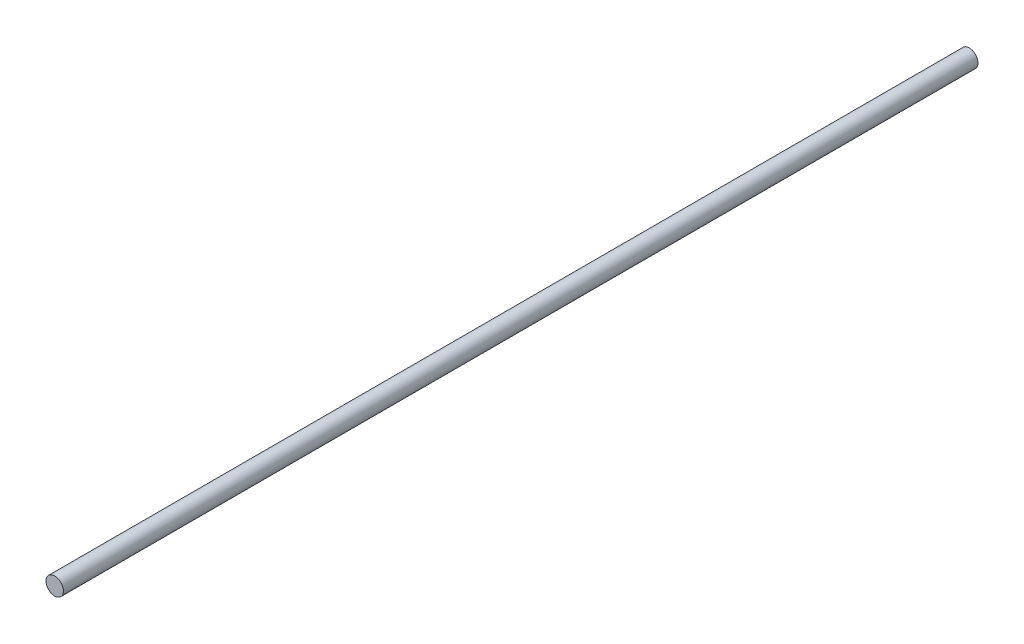
from build123d import *

# Parameters (mm, degrees)
ESQUISSE1_R        = 4
BOSS_EXTRU_1_DEPTH = 420


with BuildPart() as part:
    # Esquisse1 → Boss.-Extru.1 (new body)
    with BuildSketch(Plane.XY):
        Circle(ESQUISSE1_R)
    extrude(amount=BOSS_EXTRU_1_DEPTH)


solid = part.part
